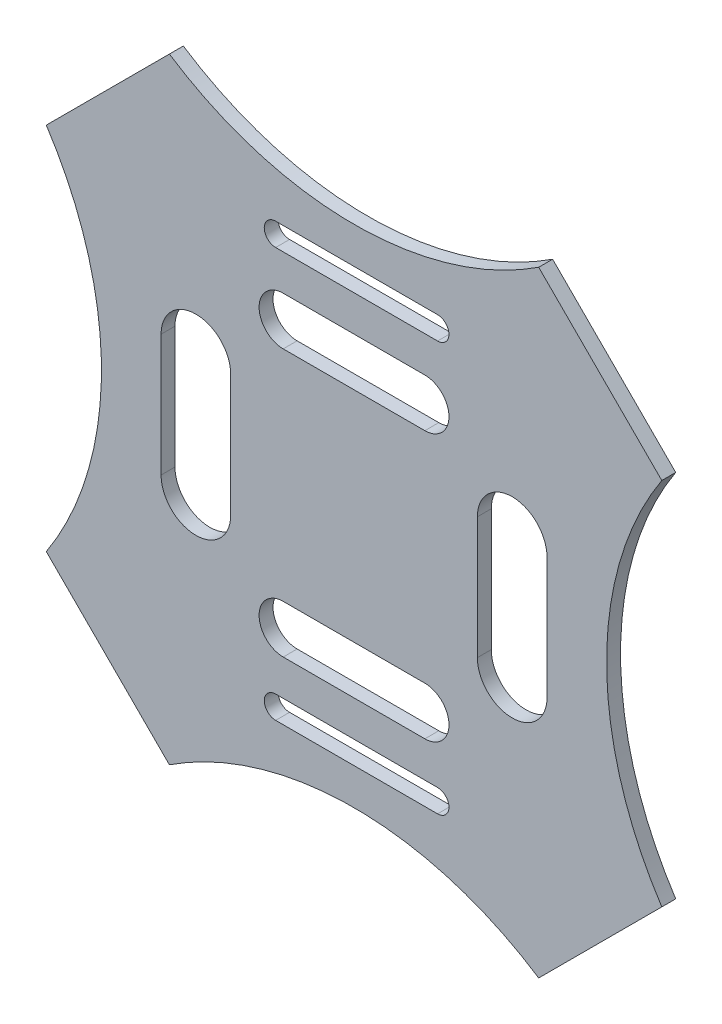
from build123d import *

# Parameters (mm, degrees)
BOSS_EXTRUDE1_DEPTH = 2
CUT_EXTRUDE1_DEPTH  = 10


with BuildPart() as part:
    # Sketch1 → Boss-Extrude1 (new body)
    with BuildSketch(Plane.XY):
        with BuildLine():
            Line((-26.516504294, 44.194173824), (-44.194173824, 26.516504294))
            ThreePointArc((-44.194173824, 26.516504294), (-36.270318491, 0), (-44.194173824, -26.516504294))
            Line((-44.194173824, -26.516504294), (-26.516504294, -44.194173824))
            ThreePointArc((-26.516504294, -44.194173824), (0, -36.270318491), (26.516504294, -44.194173824))
            Line((26.516504294, -44.194173824), (44.194173824, -26.516504294))
            ThreePointArc((44.194173824, -26.516504294), (36.270318491, 0), (44.194173824, 26.516504294))
            Line((44.194173824, 26.516504294), (26.516504294, 44.194173824))
            ThreePointArc((26.516504294, 44.194173824), (0, 36.270318491), (-26.516504294, 44.194173824))
        make_face()
    extrude(amount=BOSS_EXTRUDE1_DEPTH)

    # Sketch2 → Cut-Extrude1 (cut)
    with BuildSketch(Plane(origin=(0, 0, 0), x_dir=(-1, 0, 0), z_dir=(0, 0, -1))):
        with BuildLine():
            Line((-27.708756501, -8.757507261), (-27.708756501, 8.757507261))
            ThreePointArc((-27.708756501, 8.757507261), (-22.708756501, 13.757507261), (-17.708756501, 8.757507261))
            Line((-17.708756501, 8.757507261), (-17.708756501, -8.757507261))
            ThreePointArc((-17.708756501, -8.757507261), (-22.708756501, -13.757507261), (-27.708756501, -8.757507261))
        make_face()
        with BuildLine():
            Line((27.708756501, -8.757507261), (27.708756501, 8.757507261))
            ThreePointArc((27.708756501, 8.757507261), (22.708756501, 13.757507261), (17.708756501, 8.757507261))
            Line((17.708756501, 8.757507261), (17.708756501, -8.757507261))
            ThreePointArc((17.708756501, -8.757507261), (22.708756501, -13.757507261), (27.708756501, -8.757507261))
        make_face()
        with BuildLine():
            Line((-10.171642348, 22.620712564), (10.171642348, 22.620712564))
            ThreePointArc((10.171642348, 22.620712564), (13.631363465, 19.160991447), (10.171642348, 15.70127033))
            Line((10.171642348, 15.70127033), (-10.171642348, 15.70127033))
            ThreePointArc((-10.171642348, 15.70127033), (-13.631363465, 19.160991447), (-10.171642348, 22.620712564))
        make_face()
        with BuildLine():
            Line((-11.993928965, 31.0398289), (11.256357494, 31.0398289))
            ThreePointArc((11.256357494, 31.0398289), (12.893791994, 29.402394399), (11.256357494, 27.764959899))
            Line((11.256357494, 27.764959899), (-11.993928965, 27.764959899))
            ThreePointArc((-11.993928965, 27.764959899), (-13.631363465, 29.402394399), (-11.993928965, 31.0398289))
        make_face()
        with BuildLine():
            Line((-10.171642348, -22.620712564), (10.171642348, -22.620712564))
            ThreePointArc((10.171642348, -22.620712564), (13.631363465, -19.160991447), (10.171642348, -15.70127033))
            Line((10.171642348, -15.70127033), (-10.171642348, -15.70127033))
            ThreePointArc((-10.171642348, -15.70127033), (-13.631363465, -19.160991447), (-10.171642348, -22.620712564))
        make_face()
        with BuildLine():
            Line((-11.993928965, -31.0398289), (11.256357494, -31.0398289))
            ThreePointArc((11.256357494, -31.0398289), (12.893791994, -29.402394399), (11.256357494, -27.764959899))
            Line((11.256357494, -27.764959899), (-11.993928965, -27.764959899))
            ThreePointArc((-11.993928965, -27.764959899), (-13.631363465, -29.402394399), (-11.993928965, -31.0398289))
        make_face()
    extrude(amount=-CUT_EXTRUDE1_DEPTH, mode=Mode.SUBTRACT)


solid = part.part
